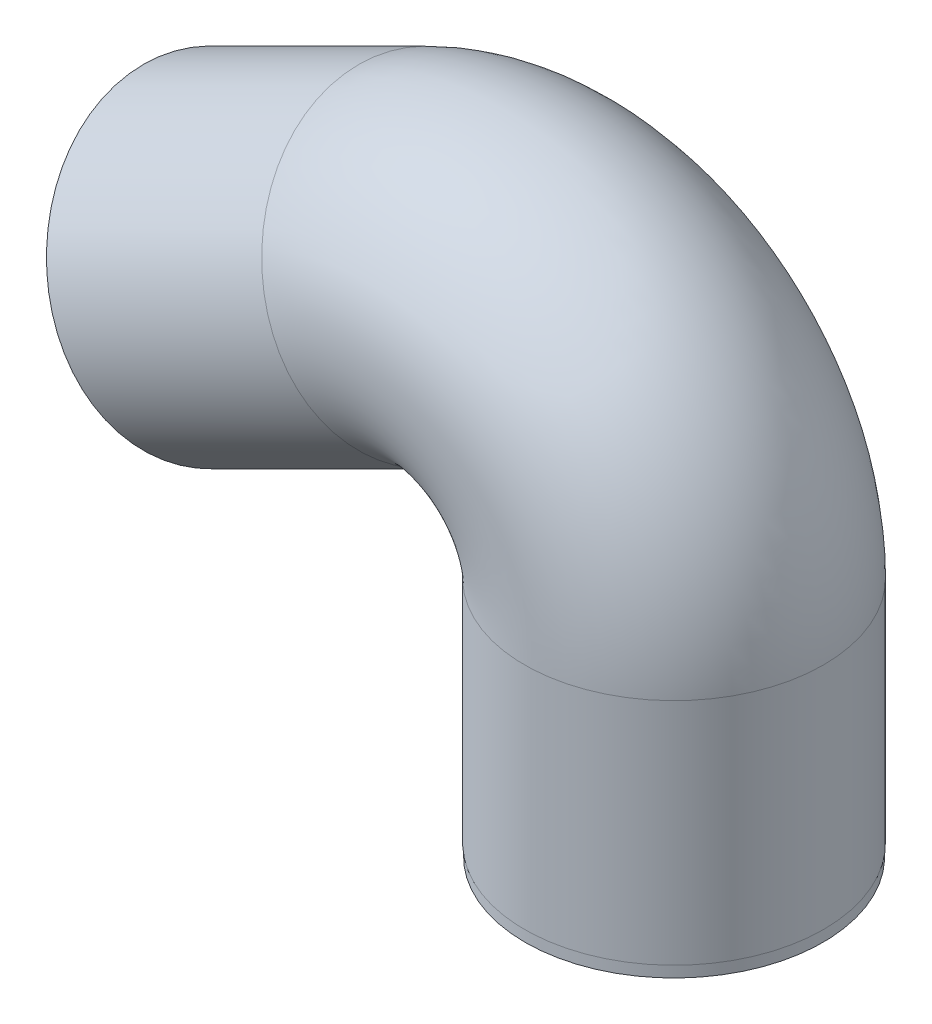
from build123d import *

# Parameters (mm, degrees)
CROQUIS1_R                 = 13
CROQUIS1_R_2               = 11.05
SALIENTE_EXTRUIR1_DEPTH    = 1
BARRER_L_MINA1_PROFILE_R   = 13.05
BARRER_L_MINA1_PROFILE_R_2 = 11.05


with BuildPart() as part:
    # Croquis1 → Saliente-Extruir1 (new body)
    with BuildSketch(Plane(origin=(0, 0, 0), x_dir=(1, 0, 0), z_dir=(0, 1, 0))):
        with Locations(Location((0, 0, 0), (0, 0, 270))):
            Circle(CROQUIS1_R)
        with Locations(Location((0, 0, 0), (0, 0, 270))):
            Circle(CROQUIS1_R_2, mode=Mode.SUBTRACT)
    extrude(amount=SALIENTE_EXTRUIR1_DEPTH)

    # Barrer-L_mina1: sweep along a path in Croquis2
    with BuildLine(Plane.XY) as barrer_l_mina1_path:
        Line((0, 1), (0, 21))
        ThreePointArc((0, 21), (-7.11124406, 33.758037847), (-21.702337296, 34.41933958))
        Line((-21.702337296, 34.41933958), (-40.489412708, 25.036067367))
    # Barrer-L_mina1 profile (on start of the path) → Barrer-L_mina1 (sweep)
    with BuildSketch(Plane.ZX.offset(1)):
        Circle(BARRER_L_MINA1_PROFILE_R)
        Circle(BARRER_L_MINA1_PROFILE_R_2, mode=Mode.SUBTRACT)
    sweep(path=barrer_l_mina1_path.line)


solid = part.part
